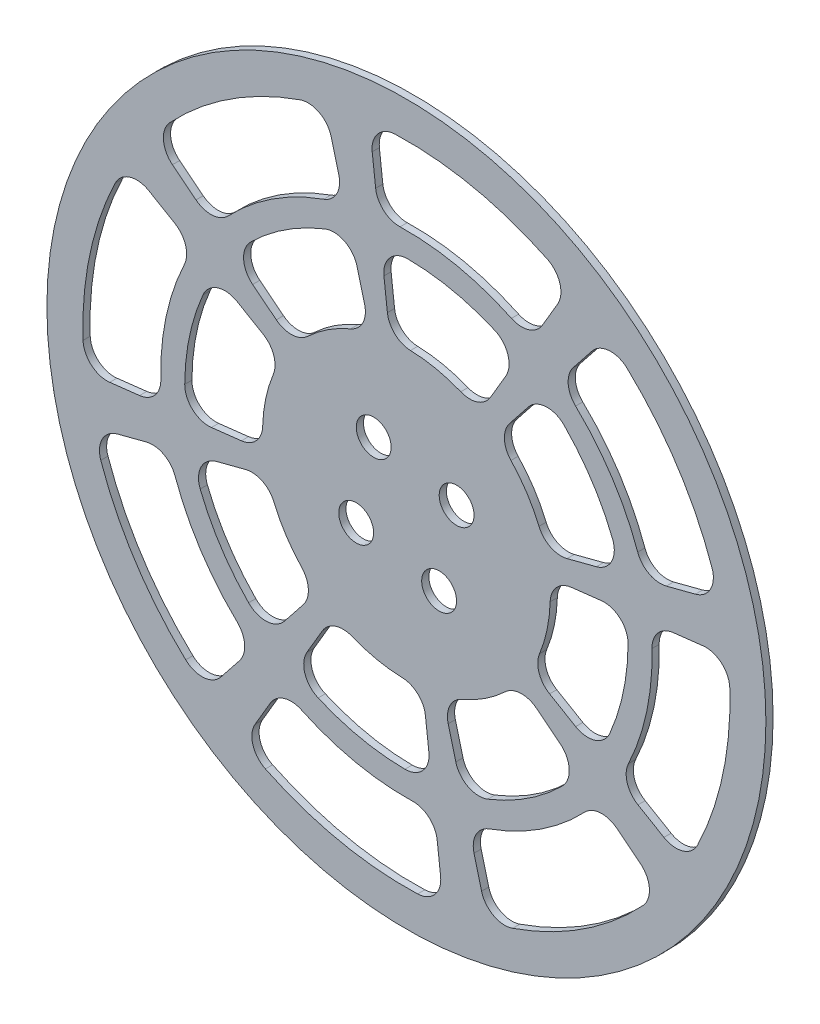
from build123d import *

# Parameters (mm, degrees)
SKETCH1_R                               = 150
BOSS_EXTRUDE2_DEPTH                     = 3
CBORE_FOR_M6_HEX_HEAD_BOLT1_D           = 6.6
CBORE_FOR_M6_HEX_HEAD_BOLT1_CBORE_D     = 14.55
CBORE_FOR_M6_HEX_HEAD_BOLT1_CBORE_DEPTH = 4.38
CUTOUTS_DEPTH                           = 4


with BuildPart() as part:
    # Sketch1 → Boss-Extrude2 (new body)
    with BuildSketch(Plane.XY):
        Circle(SKETCH1_R)
    extrude(amount=BOSS_EXTRUDE2_DEPTH)

    # CBORE for M6 Hex Head Bolt1 (through all)
    with Locations(Plane(origin=(0, 0, 0), x_dir=(-1, 0, 0), z_dir=(0, 0, -1))):
        with Locations((-20.948618644, 13.643876902), (13.643876902, 20.948618644), (20.948618644, -13.643876902), (-13.643876902, -20.948618644)):
            CounterBoreHole(CBORE_FOR_M6_HEX_HEAD_BOLT1_D / 2, CBORE_FOR_M6_HEX_HEAD_BOLT1_CBORE_D / 2, CBORE_FOR_M6_HEX_HEAD_BOLT1_CBORE_DEPTH)

    # Weight Reduction → Cutouts (cut, through all)
    with BuildSketch(Plane.XY):
        with BuildLine():
            Line((-97.615649783, 77.435036757), (-87.787690156, 69.638864559))
            ThreePointArc((-87.787690156, 69.638864559), (-80.870801235, 67.497909123), (-74.322037678, 70.586717698))
            ThreePointArc((-74.322037678, 70.586717698), (-55.939895299, 85.889336439), (-34.511783098, 96.515215523))
            ThreePointArc((-34.511783098, 96.515215523), (-29.038997546, 101.256065744), (-28.200651817, 108.4480209))
            Line((-28.200651817, 108.4480209), (-31.357755814, 120.58893461))
            ThreePointArc((-31.357755814, 120.58893461), (-36.321239681, 126.891095211), (-44.318761551, 127.518027646))
            ThreePointArc((-44.318761551, 127.518027646), (-73.676935272, 113.122540676), (-98.713002035, 92.090950854))
            ThreePointArc((-98.713002035, 92.090950854), (-101.373014269, 84.522745304), (-97.615649783, 77.435036757))
        make_face()
        with BuildLine():
            Line((-64.156921223, 50.893412728), (-54.278053379, 43.056856845))
            ThreePointArc((-54.278053379, 43.056856845), (-47.632425677, 40.900507328), (-41.197141206, 43.621044881))
            ThreePointArc((-41.197141206, 43.621044881), (-32.745304565, 50.276684745), (-23.240787477, 55.316053705))
            ThreePointArc((-23.240787477, 55.316053705), (-18.150711792, 60.102006098), (-17.436117546, 67.052082778))
            Line((-17.436117546, 67.052082778), (-20.609575145, 79.255885664))
            ThreePointArc((-20.609575145, 79.255885664), (-25.756719103, 85.653800638), (-33.958947189, 86.04091995))
            ThreePointArc((-33.958947189, 86.04091995), (-50.482344538, 77.509888981), (-64.96549613, 65.846293082))
            ThreePointArc((-64.96549613, 65.846293082), (-67.927610784, 58.187815184), (-64.156921223, 50.893412728))
        make_face()
        with BuildLine():
            Line((-14.269848319, 123.779527503), (-12.83315765, 111.317384378))
            ThreePointArc((-12.83315765, 111.317384378), (-9.456062696, 104.91252121), (-2.641270088, 102.46596358))
            ThreePointArc((-2.641270088, 102.46596358), (21.177452923, 100.288411532), (43.843047524, 92.650079243))
            ThreePointArc((43.843047524, 92.650079243), (51.06517864, 92.132522807), (56.743458851, 96.625203118))
            Line((56.743458851, 96.625203118), (63.09597162, 107.442535178))
            ThreePointArc((63.09597162, 107.442535178), (64.042559017, 115.408548775), (58.830765246, 121.506958898))
            ThreePointArc((58.830765246, 121.506958898), (27.892255069, 132.087176165), (-4.682497295, 134.918768965))
            ThreePointArc((-4.682497295, 134.918768965), (-11.91493945, 131.448152188), (-14.269848319, 123.779527503))
        make_face()
        with BuildLine():
            Line((-9.378716799, 81.352871315), (-7.934584162, 68.826175066))
            ThreePointArc((-7.934584162, 68.826175066), (-4.760185115, 62.602237286), (1.713958725, 59.97551455))
            ThreePointArc((1.713958725, 59.97551455), (12.396557808, 58.705411629), (22.680638258, 55.548075108))
            ThreePointArc((22.680638258, 55.548075108), (29.664044684, 55.333027466), (35.083785471, 59.74217938))
            Line((35.083785471, 59.74217938), (41.469203859, 70.615544544))
            ThreePointArc((41.469203859, 70.615544544), (42.353632527, 78.779134004), (36.827516116, 84.852719795))
            ThreePointArc((36.827516116, 84.852719795), (19.111359955, 90.504176261), (0.622817498, 92.497903211))
            ThreePointArc((0.622817498, 92.497903211), (-6.887075517, 89.177072914), (-9.378716799, 81.352871315))
        make_face()
        with BuildLine():
            Line((77.435036757, 97.615649783), (69.638864559, 87.787690156))
            ThreePointArc((69.638864559, 87.787690156), (67.497909123, 80.870801235), (70.586717698, 74.322037678))
            ThreePointArc((70.586717698, 74.322037678), (85.889336439, 55.939895299), (96.515215523, 34.511783098))
            ThreePointArc((96.515215523, 34.511783098), (101.256065744, 29.038997546), (108.4480209, 28.200651817))
            Line((108.4480209, 28.200651817), (120.58893461, 31.357755814))
            ThreePointArc((120.58893461, 31.357755814), (126.891095211, 36.321239681), (127.518027646, 44.318761551))
            ThreePointArc((127.518027646, 44.318761551), (113.122540676, 73.676935272), (92.090950854, 98.713002035))
            ThreePointArc((92.090950854, 98.713002035), (84.522745304, 101.373014269), (77.435036757, 97.615649783))
        make_face()
        with BuildLine():
            Line((50.893412728, 64.156921223), (43.056856845, 54.278053379))
            ThreePointArc((43.056856845, 54.278053379), (40.900507328, 47.632425677), (43.621044881, 41.197141206))
            ThreePointArc((43.621044881, 41.197141206), (50.276684745, 32.745304565), (55.316053705, 23.240787477))
            ThreePointArc((55.316053705, 23.240787477), (60.102006098, 18.150711792), (67.052082778, 17.436117546))
            Line((67.052082778, 17.436117546), (79.255885664, 20.609575145))
            ThreePointArc((79.255885664, 20.609575145), (85.653800638, 25.756719103), (86.04091995, 33.958947189))
            ThreePointArc((86.04091995, 33.958947189), (77.509888981, 50.482344538), (65.846293082, 64.96549613))
            ThreePointArc((65.846293082, 64.96549613), (58.187815184, 67.927610784), (50.893412728, 64.156921223))
        make_face()
        with BuildLine():
            Line((123.779527503, 14.269848319), (111.317384378, 12.83315765))
            ThreePointArc((111.317384378, 12.83315765), (104.91252121, 9.456062696), (102.46596358, 2.641270088))
            ThreePointArc((102.46596358, 2.641270088), (100.288411532, -21.177452923), (92.650079243, -43.843047524))
            ThreePointArc((92.650079243, -43.843047524), (92.132522807, -51.06517864), (96.625203118, -56.743458851))
            Line((96.625203118, -56.743458851), (107.442535178, -63.09597162))
            ThreePointArc((107.442535178, -63.09597162), (115.408548775, -64.042559017), (121.506958898, -58.830765246))
            ThreePointArc((121.506958898, -58.830765246), (132.087176165, -27.892255069), (134.918768965, 4.682497295))
            ThreePointArc((134.918768965, 4.682497295), (131.448152188, 11.91493945), (123.779527503, 14.269848319))
        make_face()
        with BuildLine():
            Line((81.352871315, 9.378716799), (68.826175066, 7.934584162))
            ThreePointArc((68.826175066, 7.934584162), (62.602237286, 4.760185115), (59.97551455, -1.713958725))
            ThreePointArc((59.97551455, -1.713958725), (58.705411629, -12.396557808), (55.548075108, -22.680638258))
            ThreePointArc((55.548075108, -22.680638258), (55.333027466, -29.664044684), (59.74217938, -35.083785471))
            Line((59.74217938, -35.083785471), (70.615544544, -41.469203859))
            ThreePointArc((70.615544544, -41.469203859), (78.779134004, -42.353632527), (84.852719795, -36.827516116))
            ThreePointArc((84.852719795, -36.827516116), (90.504176261, -19.111359955), (92.497903211, -0.622817498))
            ThreePointArc((92.497903211, -0.622817498), (89.177072914, 6.887075517), (81.352871315, 9.378716799))
        make_face()
        with BuildLine():
            Line((97.615649783, -77.435036757), (87.787690156, -69.638864559))
            ThreePointArc((87.787690156, -69.638864559), (80.870801235, -67.497909123), (74.322037678, -70.586717698))
            ThreePointArc((74.322037678, -70.586717698), (55.939895299, -85.889336439), (34.511783098, -96.515215523))
            ThreePointArc((34.511783098, -96.515215523), (29.038997546, -101.256065744), (28.200651817, -108.4480209))
            Line((28.200651817, -108.4480209), (31.357755814, -120.58893461))
            ThreePointArc((31.357755814, -120.58893461), (36.321239681, -126.891095211), (44.318761551, -127.518027646))
            ThreePointArc((44.318761551, -127.518027646), (73.676935272, -113.122540676), (98.713002035, -92.090950854))
            ThreePointArc((98.713002035, -92.090950854), (101.373014269, -84.522745304), (97.615649783, -77.435036757))
        make_face()
        with BuildLine():
            Line((64.156921223, -50.893412728), (54.278053379, -43.056856845))
            ThreePointArc((54.278053379, -43.056856845), (47.632425677, -40.900507328), (41.197141206, -43.621044881))
            ThreePointArc((41.197141206, -43.621044881), (32.745304565, -50.276684745), (23.240787477, -55.316053705))
            ThreePointArc((23.240787477, -55.316053705), (18.150711792, -60.102006098), (17.436117546, -67.052082778))
            Line((17.436117546, -67.052082778), (20.609575145, -79.255885664))
            ThreePointArc((20.609575145, -79.255885664), (25.756719103, -85.653800638), (33.958947189, -86.04091995))
            ThreePointArc((33.958947189, -86.04091995), (50.482344538, -77.509888981), (64.96549613, -65.846293082))
            ThreePointArc((64.96549613, -65.846293082), (67.927610784, -58.187815184), (64.156921223, -50.893412728))
        make_face()
        with BuildLine():
            Line((14.269848319, -123.779527503), (12.83315765, -111.317384378))
            ThreePointArc((12.83315765, -111.317384378), (9.456062696, -104.91252121), (2.641270088, -102.46596358))
            ThreePointArc((2.641270088, -102.46596358), (-21.177452923, -100.288411532), (-43.843047524, -92.650079243))
            ThreePointArc((-43.843047524, -92.650079243), (-51.06517864, -92.132522807), (-56.743458851, -96.625203118))
            Line((-56.743458851, -96.625203118), (-63.09597162, -107.442535178))
            ThreePointArc((-63.09597162, -107.442535178), (-64.042559017, -115.408548775), (-58.830765246, -121.506958898))
            ThreePointArc((-58.830765246, -121.506958898), (-27.892255069, -132.087176165), (4.682497295, -134.918768965))
            ThreePointArc((4.682497295, -134.918768965), (11.91493945, -131.448152188), (14.269848319, -123.779527503))
        make_face()
        with BuildLine():
            Line((9.378716799, -81.352871315), (7.934584162, -68.826175066))
            ThreePointArc((7.934584162, -68.826175066), (4.760185115, -62.602237286), (-1.713958725, -59.97551455))
            ThreePointArc((-1.713958725, -59.97551455), (-12.396557808, -58.705411629), (-22.680638258, -55.548075108))
            ThreePointArc((-22.680638258, -55.548075108), (-29.664044684, -55.333027466), (-35.083785471, -59.74217938))
            Line((-35.083785471, -59.74217938), (-41.469203859, -70.615544544))
            ThreePointArc((-41.469203859, -70.615544544), (-42.353632527, -78.779134004), (-36.827516116, -84.852719795))
            ThreePointArc((-36.827516116, -84.852719795), (-19.111359955, -90.504176261), (-0.622817498, -92.497903211))
            ThreePointArc((-0.622817498, -92.497903211), (6.887075517, -89.177072914), (9.378716799, -81.352871315))
        make_face()
        with BuildLine():
            Line((-77.435036757, -97.615649783), (-69.638864559, -87.787690156))
            ThreePointArc((-69.638864559, -87.787690156), (-67.497909123, -80.870801235), (-70.586717698, -74.322037678))
            ThreePointArc((-70.586717698, -74.322037678), (-85.889336439, -55.939895299), (-96.515215523, -34.511783098))
            ThreePointArc((-96.515215523, -34.511783098), (-101.256065744, -29.038997546), (-108.4480209, -28.200651817))
            Line((-108.4480209, -28.200651817), (-120.58893461, -31.357755814))
            ThreePointArc((-120.58893461, -31.357755814), (-126.891095211, -36.321239681), (-127.518027646, -44.318761551))
            ThreePointArc((-127.518027646, -44.318761551), (-113.122540676, -73.676935272), (-92.090950854, -98.713002035))
            ThreePointArc((-92.090950854, -98.713002035), (-84.522745304, -101.373014269), (-77.435036757, -97.615649783))
        make_face()
        with BuildLine():
            Line((-50.893412728, -64.156921223), (-43.056856845, -54.278053379))
            ThreePointArc((-43.056856845, -54.278053379), (-40.900507328, -47.632425677), (-43.621044881, -41.197141206))
            ThreePointArc((-43.621044881, -41.197141206), (-50.276684745, -32.745304565), (-55.316053705, -23.240787477))
            ThreePointArc((-55.316053705, -23.240787477), (-60.102006098, -18.150711792), (-67.052082778, -17.436117546))
            Line((-67.052082778, -17.436117546), (-79.255885664, -20.609575145))
            ThreePointArc((-79.255885664, -20.609575145), (-85.653800638, -25.756719103), (-86.04091995, -33.958947189))
            ThreePointArc((-86.04091995, -33.958947189), (-77.509888981, -50.482344538), (-65.846293082, -64.96549613))
            ThreePointArc((-65.846293082, -64.96549613), (-58.187815184, -67.927610784), (-50.893412728, -64.156921223))
        make_face()
        with BuildLine():
            Line((-123.779527503, -14.269848319), (-111.317384378, -12.83315765))
            ThreePointArc((-111.317384378, -12.83315765), (-104.91252121, -9.456062696), (-102.46596358, -2.641270088))
            ThreePointArc((-102.46596358, -2.641270088), (-100.288411532, 21.177452923), (-92.650079243, 43.843047524))
            ThreePointArc((-92.650079243, 43.843047524), (-92.132522807, 51.06517864), (-96.625203118, 56.743458851))
            Line((-96.625203118, 56.743458851), (-107.442535178, 63.09597162))
            ThreePointArc((-107.442535178, 63.09597162), (-115.408548775, 64.042559017), (-121.506958898, 58.830765246))
            ThreePointArc((-121.506958898, 58.830765246), (-132.087176165, 27.892255069), (-134.918768965, -4.682497295))
            ThreePointArc((-134.918768965, -4.682497295), (-131.448152188, -11.91493945), (-123.779527503, -14.269848319))
        make_face()
        with BuildLine():
            Line((-81.352871315, -9.378716799), (-68.826175066, -7.934584162))
            ThreePointArc((-68.826175066, -7.934584162), (-62.602237286, -4.760185115), (-59.97551455, 1.713958725))
            ThreePointArc((-59.97551455, 1.713958725), (-58.705411629, 12.396557808), (-55.548075108, 22.680638258))
            ThreePointArc((-55.548075108, 22.680638258), (-55.333027466, 29.664044684), (-59.74217938, 35.083785471))
            Line((-59.74217938, 35.083785471), (-70.615544544, 41.469203859))
            ThreePointArc((-70.615544544, 41.469203859), (-78.779134004, 42.353632527), (-84.852719795, 36.827516116))
            ThreePointArc((-84.852719795, 36.827516116), (-90.504176261, 19.111359955), (-92.497903211, 0.622817498))
            ThreePointArc((-92.497903211, 0.622817498), (-89.177072914, -6.887075517), (-81.352871315, -9.378716799))
        make_face()
    extrude(amount=CUTOUTS_DEPTH, mode=Mode.SUBTRACT)


solid = part.part
